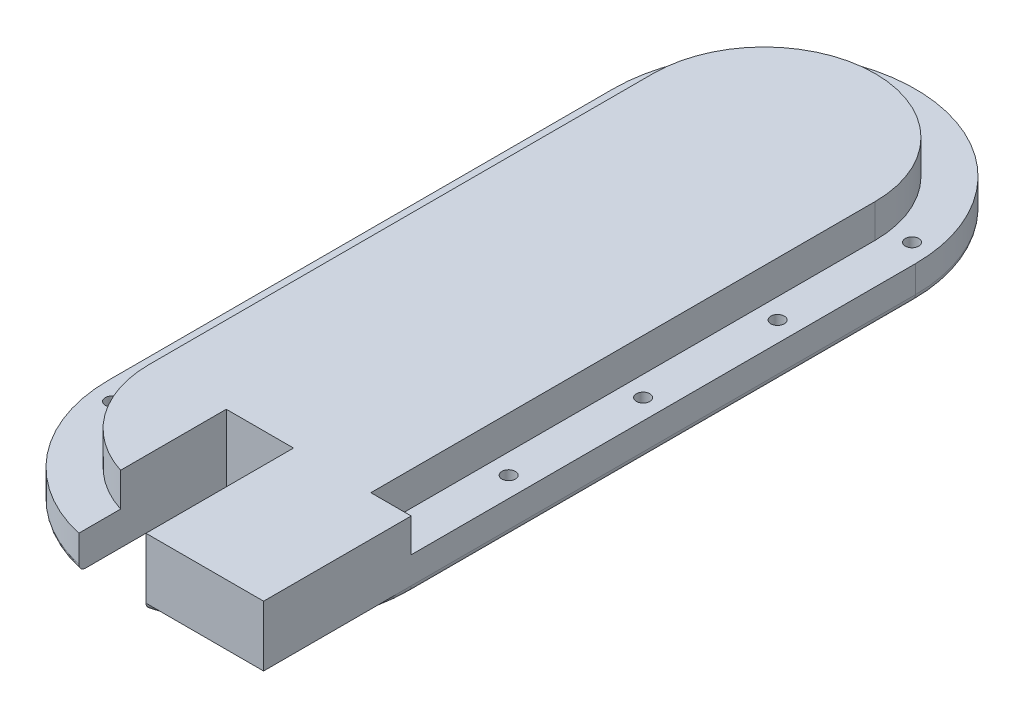
from build123d import *

# Parameters (mm, degrees)
BOSS_EXTRUDE1_DEPTH = 20
FILLET1_R           = 2
SKETCH4_R           = 11
CUT_EXTRUDE2_DEPTH  = 6.35
SKETCH5_OUTSIDE_W   = 143.42
SKETCH5_OUTSIDE_H   = 293.42
CUT_EXTRUDE3_DEPTH  = 10
SKETCH7_R           = 2
CUT_EXTRUDE4_DEPTH  = 11
SKETCH9_W           = 20
SKETCH9_H           = 50.969748303
CUT_EXTRUDE6_DEPTH  = 21
SKETCH10_W          = 35
SKETCH10_H          = 18
BOSS_EXTRUDE2_DEPTH = 43.9


with BuildPart() as part:
    # Sketch1 → Boss-Extrude1 (new body)
    with BuildSketch(Plane(origin=(0, 0, 0), x_dir=(1, 0, 0), z_dir=(0, 1, 0))):
        with BuildLine():
            Line((0, 0), (0, 150))
            ThreePointArc((0, 150), (-45, 195), (-90, 150))
            Line((-90, 150), (-90, 0))
            ThreePointArc((-90, 0), (-45, -45), (0, 0))
        make_face()
    extrude(amount=-BOSS_EXTRUDE1_DEPTH)

    # Fillet1
    fillet1_edges = [part.edges().sort_by_distance(p)[0] for p in [
        (-45, -20, -195),
        (-90, -20, -75),
        (-45, -20, 45),
        (-90, 0, -75),
        (-45, 0, -195),
        (0, 0, -75),
        (-45, 0, 45),
        (0, -20, -75),
    ]]
    fillet(fillet1_edges, radius=FILLET1_R)

    # Sketch4 → Cut-Extrude2 (cut)
    with BuildSketch(Plane.XZ.offset(20)):
        with Locations((-45.5, -150)):
            Circle(SKETCH4_R)
    extrude(amount=-CUT_EXTRUDE2_DEPTH, mode=Mode.SUBTRACT)

    # Sketch5 outside → Cut-Extrude3 (cut)
    with BuildSketch(Plane(origin=(0, 0, 0), x_dir=(1, 0, 0), z_dir=(0, 1, 0))):
        with Locations((-45, 75)):
            Rectangle(SKETCH5_OUTSIDE_W, SKETCH5_OUTSIDE_H)
        with BuildLine():
            Line((-78, 0), (-78, 150))
            ThreePointArc((-78, 150), (-45, 183), (-12, 150))
            Line((-12, 150), (-12, 0))
            ThreePointArc((-12, 0), (-45, -33), (-78, 0))
        make_face(mode=Mode.SUBTRACT)
    extrude(amount=-CUT_EXTRUDE3_DEPTH, mode=Mode.SUBTRACT)

    # Sketch7 → Cut-Extrude4 (cut, through all)
    with BuildSketch(Plane(origin=(0, -10, 0), x_dir=(1, 0, 0), z_dir=(0, 1, 0))):
        with Locations((-6, 75)):
            Circle(SKETCH7_R)
        with Locations((-6, 115)):
            Circle(SKETCH7_R)
        with Locations((-6, 155)):
            Circle(SKETCH7_R)
        with Locations((-6, 35)):
            Circle(SKETCH7_R)
        with Locations((-6, -5)):
            Circle(SKETCH7_R)
        with Locations((-84, -5)):
            Circle(SKETCH7_R)
        with Locations((-84, 35)):
            Circle(SKETCH7_R)
        with Locations((-84, 75)):
            Circle(SKETCH7_R)
        with Locations((-84, 115)):
            Circle(SKETCH7_R)
        with Locations((-84, 155)):
            Circle(SKETCH7_R)
    extrude(amount=-CUT_EXTRUDE4_DEPTH, mode=Mode.SUBTRACT)

    # Sketch9 → Cut-Extrude6 (cut, through all)
    with BuildSketch(Plane(origin=(0, 0, 0), x_dir=(1, 0, 0), z_dir=(0, 1, 0))):
        with Locations((-45, -25.484874152)):
            Rectangle(SKETCH9_W, SKETCH9_H)
    extrude(amount=-CUT_EXTRUDE6_DEPTH, mode=Mode.SUBTRACT)

    # Sketch10 → Boss-Extrude2 (add)
    with BuildSketch(Plane.XY):
        with Locations((-17.5, -9)):
            Rectangle(SKETCH10_W, SKETCH10_H)
    extrude(amount=BOSS_EXTRUDE2_DEPTH)


solid = part.part
